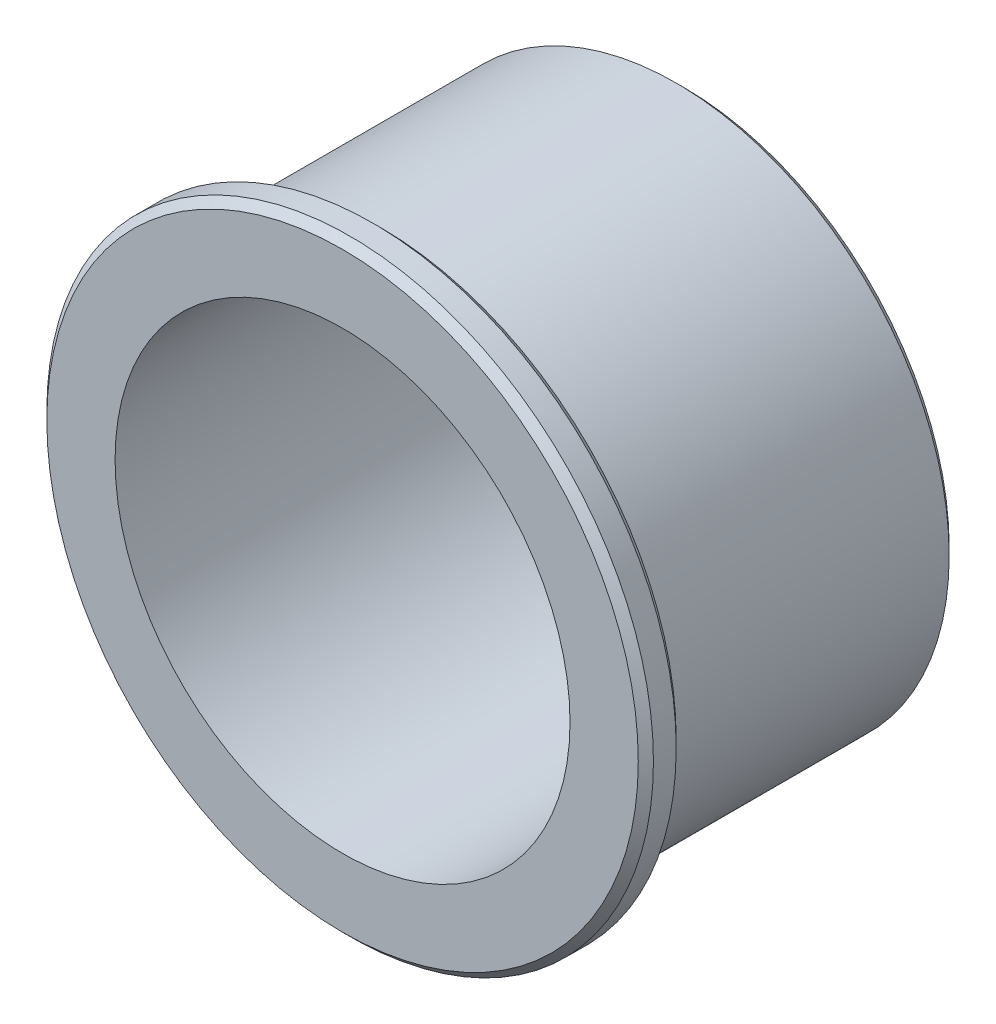
from build123d import *

# Parameters (mm, degrees)
FILLET1_R     = 0.5
CHAMFER1_SIZE = 0.5


with BuildPart() as part:
    # Sketch1 → Revolve1 (revolve)
    with BuildSketch(Plane(origin=(0, 0, 0), x_dir=(0, 0, -1), z_dir=(1, 0, 0))):
        Polygon((0, 15), (0, 20), (2.5, 20), (2.5, 18), (22.5, 18), (22.5, 15), align=None)
    revolve(axis=Axis((0, 0, 38.983478261), (0, 0, -1)))

    # Fillet1
    fillet1_edges = [part.edges().sort_by_distance(p)[0] for p in [
        (0, -18, -2.5),
    ]]
    fillet(fillet1_edges, radius=FILLET1_R)

    # Chamfer1
    chamfer1_edges = [part.edges().sort_by_distance(p)[0] for p in [
        (0, -20, -2.5),
        (0, -20, 0),
        (0, -18, -22.5),
        (0, -15, -22.5),
    ]]
    chamfer(chamfer1_edges, length=CHAMFER1_SIZE)


solid = part.part
